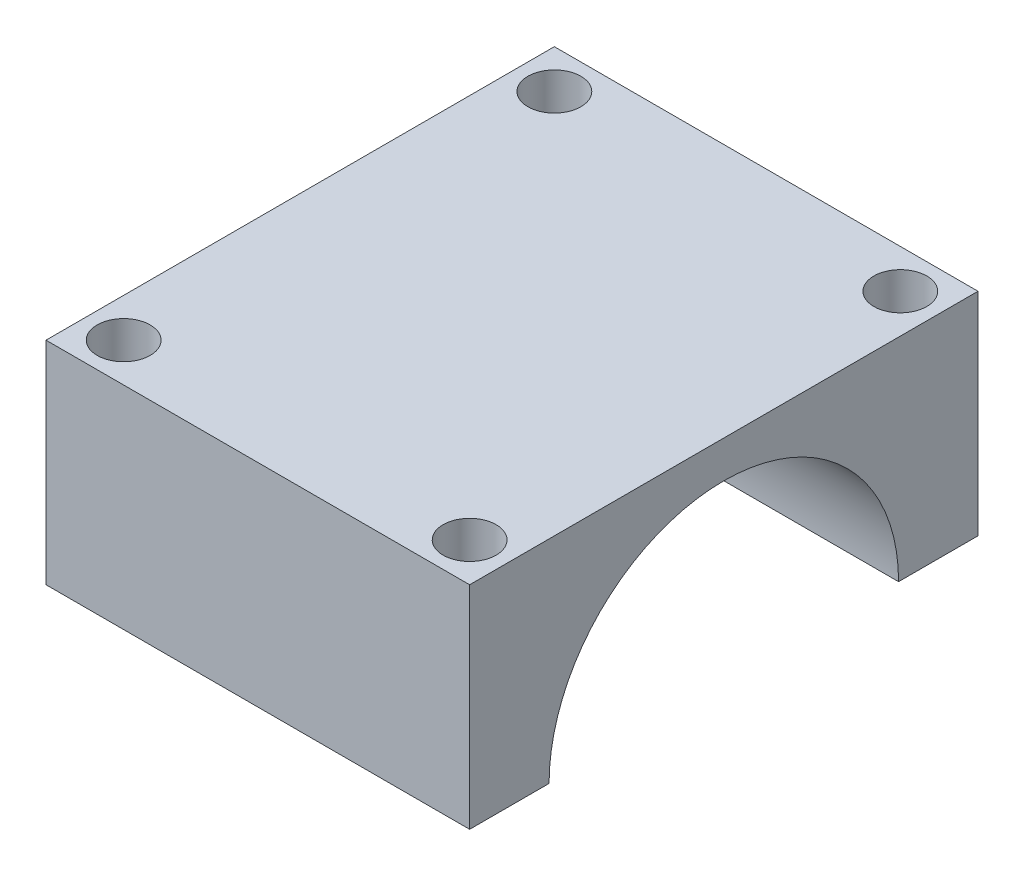
from build123d import *

# Parameters (mm, degrees)
SKETCH1_W           = 30
SKETCH1_H           = 36
BOSS_EXTRUDE1_DEPTH = 30
SKETCH3_R           = 12.375
CUT_EXTRUDE1_DEPTH  = 40
SKETCH5_R           = 1.875
CUT_EXTRUDE2_DEPTH  = 40
CUT_EXTRUDE3_START  = 15
SKETCH7_W           = 36
SKETCH7_H           = 15
CUT_EXTRUDE3_DEPTH  = 31


with BuildPart() as part:
    # Sketch1 → Boss-Extrude1 (new body)
    with BuildSketch(Plane(origin=(0, 0, 0), x_dir=(1, 0, 0), z_dir=(0, 1, 0))):
        Rectangle(SKETCH1_W, SKETCH1_H)
    extrude(amount=BOSS_EXTRUDE1_DEPTH)

    # Sketch3 → Cut-Extrude1 (cut)
    with BuildSketch(Plane(origin=(15, 0, 0), x_dir=(0, 0, -1), z_dir=(1, 0, 0))):
        with Locations((0, 15)):
            Circle(SKETCH3_R)
    extrude(amount=-CUT_EXTRUDE1_DEPTH, mode=Mode.SUBTRACT)

    # Sketch5 → Cut-Extrude2 (cut)
    with BuildSketch(Plane(origin=(0, 30, 0), x_dir=(1, 0, 0), z_dir=(0, 1, 0))):
        with Locations((-12.25, 15.25)):
            Circle(SKETCH5_R)
        with Locations((-12.25, -15.25)):
            Circle(SKETCH5_R)
        with Locations((12.25, -15.25)):
            Circle(SKETCH5_R)
        with Locations((12.25, 15.25)):
            Circle(SKETCH5_R)
    extrude(amount=-CUT_EXTRUDE2_DEPTH, mode=Mode.SUBTRACT)

    # Sketch7 → Cut-Extrude3 (cut, through all)
    with BuildSketch(Plane(origin=(0, 0, 0), x_dir=(0, 0, -1), z_dir=(1, 0, 0)).offset(CUT_EXTRUDE3_START)):
        with Locations((0, 7.5)):
            Rectangle(SKETCH7_W, SKETCH7_H)
    extrude(amount=-CUT_EXTRUDE3_DEPTH, mode=Mode.SUBTRACT)


solid = part.part
